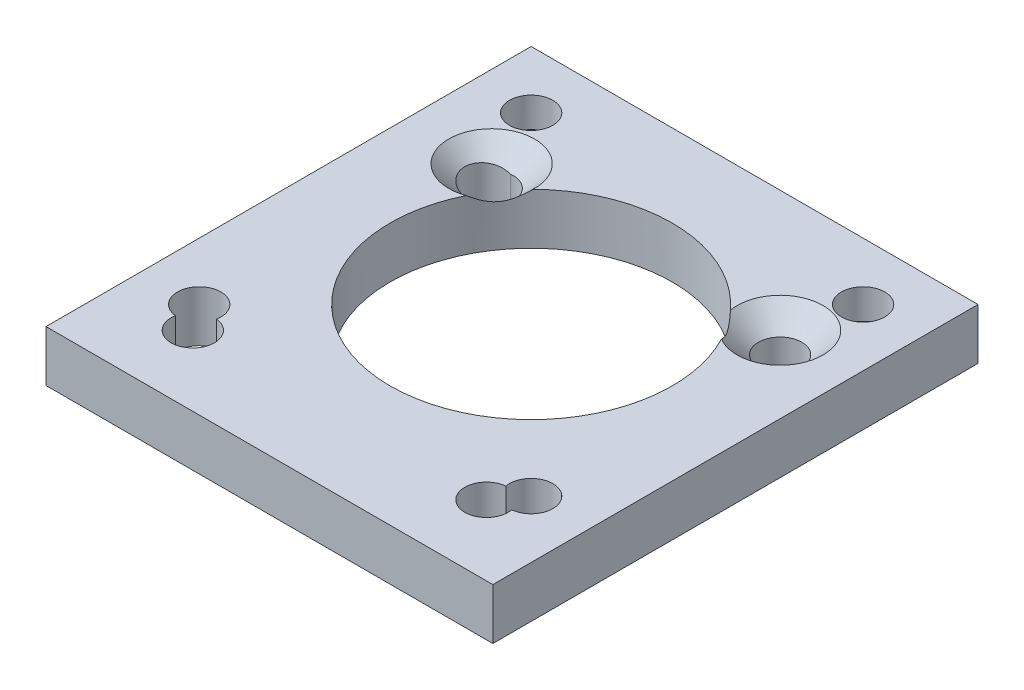
from build123d import *

# Parameters (mm, degrees)
SKETCH1_W                                            = 35
SKETCH1_H                                            = 38
BOSS_EXTRUDE1_DEPTH                                  = 4
M3_CLEARANCE_HOLE1_D                                 = 3.4
SKETCH4_R                                            = 11.05
CUT_EXTRUDE1_DEPTH                                   = 5
M3_CLEARANCE_HOLE2_D                                 = 3.4
CSK_FOR_M3_HEX_SOCKET_COUNTERSUNK_CAP_SC_D           = 3.4
CSK_FOR_M3_HEX_SOCKET_COUNTERSUNK_CAP_SC_CSINK_D     = 6.72
CSK_FOR_M3_HEX_SOCKET_COUNTERSUNK_CAP_SC_CSINK_ANGLE = 90
CSK_FOR_M3_HEX_SOCKET_COUNTERSUNK_CA_2_D             = 3.4
CSK_FOR_M3_HEX_SOCKET_COUNTERSUNK_CA_2_CSINK_D       = 6.72
CSK_FOR_M3_HEX_SOCKET_COUNTERSUNK_CA_2_CSINK_ANGLE   = 90


with BuildPart() as part:
    # Sketch1 → Boss-Extrude1 (new body)
    with BuildSketch(Plane(origin=(0, 0, 0), x_dir=(1, 0, 0), z_dir=(0, 1, 0))):
        Rectangle(SKETCH1_W, SKETCH1_H)
    extrude(amount=BOSS_EXTRUDE1_DEPTH)

    # M3 Clearance Hole1 (through all)
    with Locations(Plane(origin=(0, 0, 0), x_dir=(-1, 0, 0), z_dir=(0, -1, 0))):
        with Locations((-11.5, -13.5), (-11.5, 9.5), (11.5, 9.5), (11.5, -13.5)):
            Hole(M3_CLEARANCE_HOLE1_D / 2)

    # Sketch4 → Cut-Extrude1 (cut, through all)
    with BuildSketch(Plane(origin=(0, 4, 0), x_dir=(1, 0, 0), z_dir=(0, 1, 0))):
        with Locations((0, 1.5)):
            Circle(SKETCH4_R)
    extrude(amount=-CUT_EXTRUDE1_DEPTH, mode=Mode.SUBTRACT)

    # M3 Clearance Hole2 (through all)
    with Locations(Plane(origin=(0, 4, 0), x_dir=(1, 0, 0), z_dir=(0, 1, 0))):
        with Locations((-13, 14.5), (13, 14.5), (-13, -11.5), (13, -11.5)):
            Hole(M3_CLEARANCE_HOLE2_D / 2)

    # CSK for M3 Hex Socket Countersunk Cap Sc (through all)
    with Locations(Plane(origin=(0, 0, 0), x_dir=(-1, 0, 0), z_dir=(0, -1, 0))):
        with Locations((-13, 14.5), (13, 14.5)):
            CounterSinkHole(CSK_FOR_M3_HEX_SOCKET_COUNTERSUNK_CAP_SC_D / 2, CSK_FOR_M3_HEX_SOCKET_COUNTERSUNK_CAP_SC_CSINK_D / 2, counter_sink_angle=CSK_FOR_M3_HEX_SOCKET_COUNTERSUNK_CAP_SC_CSINK_ANGLE)

    # CSK for M3 Hex Socket Countersunk Ca 2 (through all)
    with Locations(Plane(origin=(0, 4, 0), x_dir=(1, 0, 0), z_dir=(0, 1, 0))):
        with Locations((11.5, 9.5), (-11.093205122, 9.5)):
            CounterSinkHole(CSK_FOR_M3_HEX_SOCKET_COUNTERSUNK_CA_2_D / 2, CSK_FOR_M3_HEX_SOCKET_COUNTERSUNK_CA_2_CSINK_D / 2, counter_sink_angle=CSK_FOR_M3_HEX_SOCKET_COUNTERSUNK_CA_2_CSINK_ANGLE)


solid = part.part
